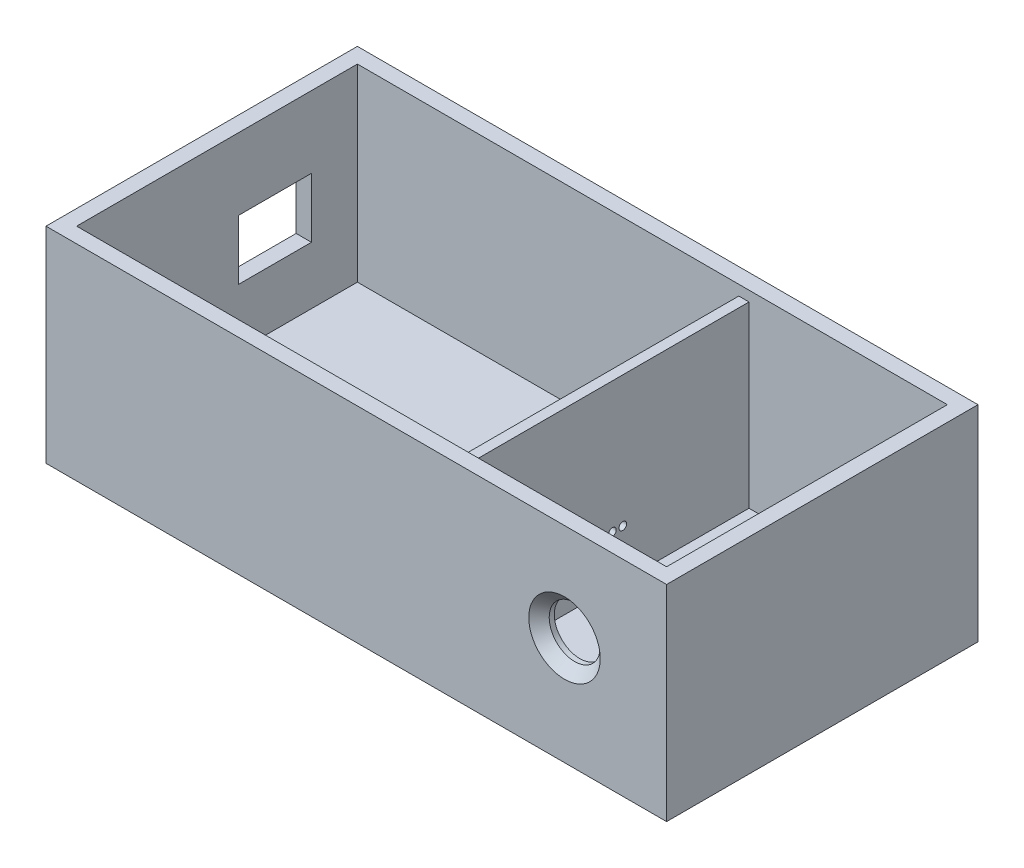
from build123d import *

# Parameters (mm, degrees)
SKETCH1_W               = 121.57
SKETCH1_H               = 61
BOSS_EXTRUDE1_DEPTH     = 3.235369433
SKETCH2_W               = 121.57
SKETCH2_H               = 61
SKETCH2_W_2             = 115.57
SKETCH2_H_2             = 55
BOSS_EXTRUDE2_DEPTH     = 37
CUT_EXTRUDE1_REACH      = 123.57
SKETCH3_W               = 14.3
SKETCH3_H               = 11.7
SKETCH5_W               = 2
SKETCH5_H               = 55
BOSS_EXTRUDE3_DEPTH     = 35
SKETCH7_R               = 5
CUT_EXTRUDE3_DEPTH      = 20
CHAMFER10_SIZE          = 2
SKETCH8_R               = 0.75
CUT_EXTRUDE4_DEPTH      = 11
CUT_EXTRUDE4_DEPTH_BACK = 17


with BuildPart() as part:
    # Sketch1 → Boss-Extrude1 (new body)
    with BuildSketch(Plane(origin=(0, 0, 0), x_dir=(1, 0, 0), z_dir=(0, 1, 0))):
        Rectangle(SKETCH1_W, SKETCH1_H)
    extrude(amount=BOSS_EXTRUDE1_DEPTH)

    # Sketch2 → Boss-Extrude2 (add)
    with BuildSketch(Plane(origin=(0, 3.235369433, 0), x_dir=(1, 0, 0), z_dir=(0, 1, 0))):
        Rectangle(SKETCH2_W, SKETCH2_H)
        Rectangle(SKETCH2_W_2, SKETCH2_H_2, mode=Mode.SUBTRACT)
    extrude(amount=BOSS_EXTRUDE2_DEPTH)

    # Sketch3 → Cut-Extrude1 (cut, up to next)
    with BuildSketch(Plane.ZY.offset(60.785), mode=Mode.PRIVATE) as cut_extrude1_sk1:
        with Locations((-11.35, 20.35)):
            Rectangle(SKETCH3_W, SKETCH3_H)
    cut_extrude1_tool1 = extrude(cut_extrude1_sk1.sketch, amount=-CUT_EXTRUDE1_REACH, mode=Mode.PRIVATE) & part.part
    add(cut_extrude1_tool1.solids().sort_by_distance((-60.785, 20.35, -11.35))[0], mode=Mode.SUBTRACT)

    # Sketch5 → Boss-Extrude3 (add)
    with BuildSketch(Plane(origin=(0, 3.235369433, 0), x_dir=(1, 0, 0), z_dir=(0, 1, 0))):
        with Locations((17.93, 0)):
            Rectangle(SKETCH5_W, SKETCH5_H)
    extrude(amount=BOSS_EXTRUDE3_DEPTH)

    # Sketch7 → Cut-Extrude3 (cut)
    with BuildSketch(Plane.XY.offset(30.5)):
        with Locations((40.785, 21.15)):
            Circle(SKETCH7_R)
    extrude(amount=-CUT_EXTRUDE3_DEPTH, mode=Mode.SUBTRACT)

    # Chamfer10
    chamfer10_edges = [part.edges().sort_by_distance(p)[0] for p in [
        (35.785, 21.15, 30.5),
    ]]
    chamfer(chamfer10_edges, length=CHAMFER10_SIZE)

    # Sketch8 → Cut-Extrude4 (cut, two sides)
    with BuildSketch(Plane.ZY.offset(-16.93)) as cut_extrude4_sk:
        with Locations((-0.737087906, 12.579188257)):
            Circle(SKETCH8_R)
        with Locations((1.278476701, 12.579188257)):
            Circle(SKETCH8_R)
        with Locations((3.44541986, 12.579188257)):
            Circle(SKETCH8_R)
        with Locations((5.769363075, 12.579188257)):
            Circle(SKETCH8_R)
        with Locations((-2.774299402, 12.579188257)):
            Circle(SKETCH8_R)
    extrude(amount=CUT_EXTRUDE4_DEPTH, mode=Mode.SUBTRACT)
    extrude(cut_extrude4_sk.sketch, amount=-CUT_EXTRUDE4_DEPTH_BACK, mode=Mode.SUBTRACT)


solid = part.part
